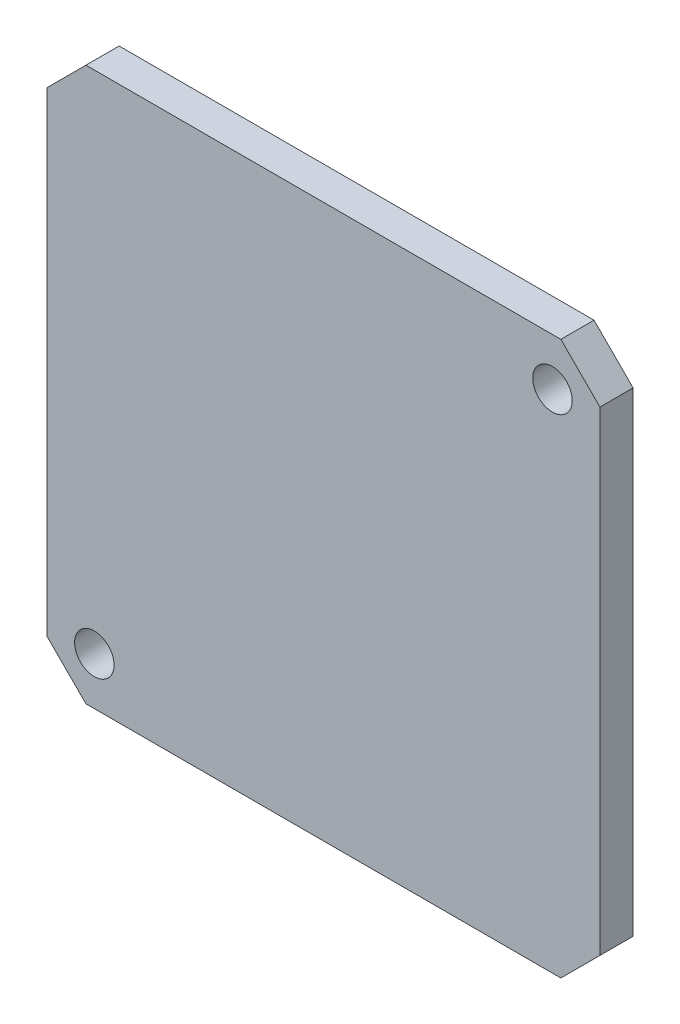
from build123d import *

# Parameters (mm, degrees)
SKETCH1_R           = 1.25
BOSS_EXTRUDE1_DEPTH = 2.1


with BuildPart() as part:
    # Sketch1 → Boss-Extrude1 (new body)
    with BuildSketch(Plane.XY):
        Polygon((-17.5, 15.026911935), (-17.5, -15.026911935), (-15.026911935, -17.5), (15.026911935, -17.5), (17.5, -15.026911935), (17.5, 15.026911935), (15.026911935, 17.5), (-15.026911935, 17.5), align=None)
        with Locations((14.495689014, 14.495689014)):
            Circle(SKETCH1_R, mode=Mode.SUBTRACT)
        with Locations((-14.495689014, -14.495689014)):
            Circle(SKETCH1_R, mode=Mode.SUBTRACT)
    extrude(amount=BOSS_EXTRUDE1_DEPTH)


solid = part.part
